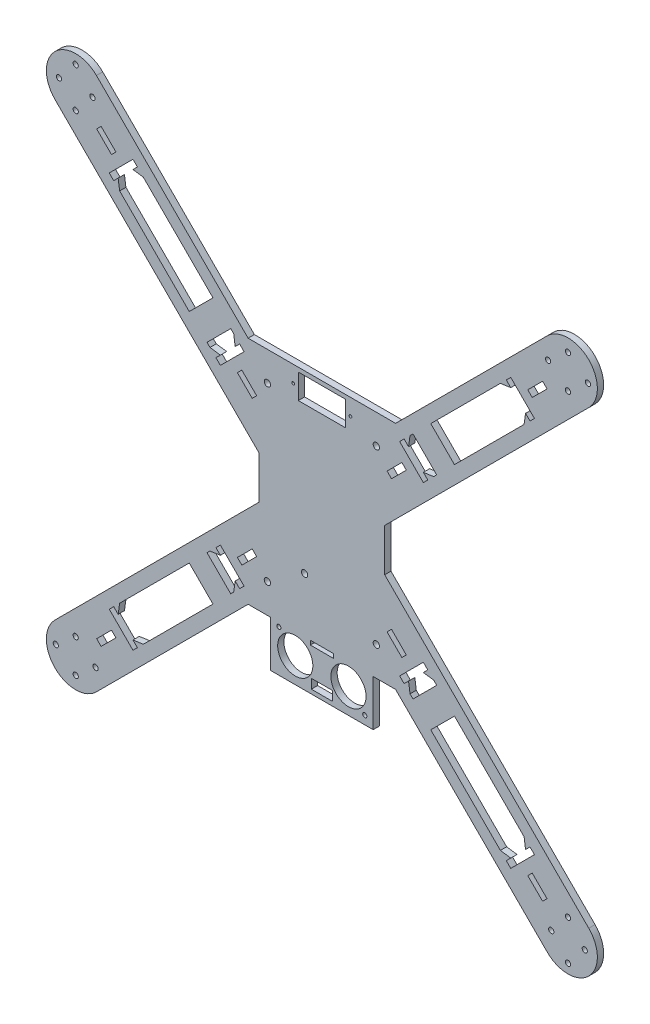
from build123d import *

# Parameters (mm, degrees)
BOSS_EXTRUDE1_DEPTH = 3
SKETCH4_R           = 1.5
SKETCH4_R_2         = 1.25
CUT_EXTRUDE1_DEPTH  = 3
SKETCH5_R           = 0.65
SKETCH5_W           = 22.5
SKETCH5_H           = 11.8
CUT_EXTRUDE2_DEPTH  = 3
SKETCH6_R           = 1.5
CUT_EXTRUDE3_DEPTH  = 3
SKETCH7_R           = 1
SKETCH7_R_2         = 8.4
SKETCH7_W           = 11
SKETCH7_H           = 2
SKETCH7_W_2         = 10
SKETCH7_H_2         = 4.5
CUT_EXTRUDE4_DEPTH  = 3
CUT_EXTRUDE5_DEPTH  = 4
BOSS_EXTRUDE2_REACH = 195.969
SKETCH9_W           = 3
SKETCH9_H           = 12
BOSS_EXTRUDE3_REACH = 195.969
SKETCH11_W          = 3
SKETCH11_H          = 12
BOSS_EXTRUDE4_REACH = 195.969
SKETCH12_W          = 3
SKETCH12_H          = 12
BOSS_EXTRUDE5_REACH = 195.969
SKETCH13_W          = 3
SKETCH13_H          = 12


with BuildPart() as part:
    # Sketch1 → Boss-Extrude1 (new body)
    with BuildSketch(Plane.XY):
        with BuildLine():
            Line((35.201010127, 55), (-35.201010127, 55))
            Line((-35.201010127, 55), (-107.600505063, 127.399494937))
            ThreePointArc((-107.600505063, 127.399494937), (-127.399494937, 127.399494937), (-127.399494937, 107.600505063))
            Line((-127.399494937, 107.600505063), (-30, 10.201010127))
            Line((-30, 10.201010127), (-30, -10.201010127))
            Line((-30, -10.201010127), (-127.399494937, -107.600505063))
            ThreePointArc((-127.399494937, -107.600505063), (-127.399494937, -127.399494937), (-107.600505063, -127.399494937))
            Line((-107.600505063, -127.399494937), (-35.201010127, -55))
            Line((-35.201010127, -55), (-24.5, -55))
            Line((-24.5, -55), (-24.5, -77))
            Line((-24.5, -77), (24.5, -77))
            Line((24.5, -77), (24.5, -55))
            Line((24.5, -55), (35.201010127, -55))
            Line((35.201010127, -55), (107.600505063, -127.399494937))
            ThreePointArc((107.600505063, -127.399494937), (127.399494937, -127.399494937), (127.399494937, -107.600505063))
            Line((127.399494937, -107.600505063), (30, -10.201010127))
            Line((30, -10.201010127), (30, 10.201010127))
            Line((30, 10.201010127), (127.399494937, 107.600505063))
            ThreePointArc((127.399494937, 107.600505063), (127.399494937, 127.399494937), (107.600505063, 127.399494937))
            Line((107.600505063, 127.399494937), (35.201010127, 55))
        make_face()
    extrude(amount=-BOSS_EXTRUDE1_DEPTH)

    # Sketch4 → Cut-Extrude1 (cut)
    with BuildSketch(Plane.XY):
        with Locations((-26, 41)):
            Circle(SKETCH4_R)
        with Locations((-26, -41)):
            Circle(SKETCH4_R)
        with Locations((26, -41)):
            Circle(SKETCH4_R)
        with Locations((26, 41)):
            Circle(SKETCH4_R)
        with Locations((-117.5, 127)):
            Circle(SKETCH4_R_2)
        with Locations((-117.5, 108)):
            Circle(SKETCH4_R_2)
        with Locations((-125.5, 117.5)):
            Circle(SKETCH4_R_2)
        with Locations((-109.5, 117.5)):
            Circle(SKETCH4_R_2)
        with Locations((117.5, 109.5)):
            Circle(SKETCH4_R_2)
        with Locations((108, 117.5)):
            Circle(SKETCH4_R_2)
        with Locations((117.5, 125.5)):
            Circle(SKETCH4_R_2)
        with Locations((127, 117.5)):
            Circle(SKETCH4_R_2)
        with Locations((109.5, -117.5)):
            Circle(SKETCH4_R_2)
        with Locations((117.5, -108)):
            Circle(SKETCH4_R_2)
        with Locations((125.5, -117.5)):
            Circle(SKETCH4_R_2)
        with Locations((117.5, -127)):
            Circle(SKETCH4_R_2)
        with Locations((-117.5, -109.5)):
            Circle(SKETCH4_R_2)
        with Locations((-108, -117.5)):
            Circle(SKETCH4_R_2)
        with Locations((-117.5, -125.5)):
            Circle(SKETCH4_R_2)
        with Locations((-127, -117.5)):
            Circle(SKETCH4_R_2)
    extrude(amount=-CUT_EXTRUDE1_DEPTH, mode=Mode.SUBTRACT)

    # Sketch5 → Cut-Extrude2 (cut)
    with BuildSketch(Plane.XY):
        with Locations((-13.65, 47.1)):
            Circle(SKETCH5_R)
        with Locations((13.65, 47.1)):
            Circle(SKETCH5_R)
        with Locations((0, 47.1)):
            Rectangle(SKETCH5_W, SKETCH5_H)
    extrude(amount=-CUT_EXTRUDE2_DEPTH, mode=Mode.SUBTRACT)

    # Sketch6 → Cut-Extrude3 (cut)
    with BuildSketch(Plane.XY):
        with Locations((-8.25, -28.8)):
            Circle(SKETCH6_R)
    extrude(amount=-CUT_EXTRUDE3_DEPTH, mode=Mode.SUBTRACT)

    # Sketch7 → Cut-Extrude4 (cut)
    with BuildSketch(Plane.XY):
        with Locations((-20.5, -57)):
            Circle(SKETCH7_R)
        with Locations((-12.7, -65)):
            Circle(SKETCH7_R_2)
        with Locations((12.7, -65)):
            Circle(SKETCH7_R_2)
        with Locations((20.5, -73)):
            Circle(SKETCH7_R)
        with Locations((0, -56)):
            Rectangle(SKETCH7_W, SKETCH7_H)
        with Locations((0, -72.75)):
            Rectangle(SKETCH7_W_2, SKETCH7_H_2)
    extrude(amount=-CUT_EXTRUDE4_DEPTH, mode=Mode.SUBTRACT)

    # Sketch8 → Cut-Extrude5 (cut, through all)
    with BuildSketch(Plane.XY):
        Polygon((101.47918472, -90.165476221), (90.165476221, -101.47918472), (88.044155877, -99.357864376), (90.165476221, -97.236544033), (85.215728753, -96.529437252), (42.0822151, -53.395923599), (41.375108319, -48.446176131), (39.253787975, -50.567496474), (37.132467632, -48.446176131), (48.446176131, -37.132467632), (50.567496474, -39.253787975), (48.446176131, -41.375108319), (53.395923599, -42.0822151), (96.529437252, -85.215728753), (97.236544033, -90.165476221), (99.357864376, -88.044155877), align=None)
        Polygon((40.314448147, -38.193127804), (38.193127804, -40.314448147), (31.122059992, -33.243380335), (33.243380335, -31.122059992), align=None)
        Polygon((50.567496474, 39.253787975), (48.446176131, 37.132467632), (37.132467632, 48.446176131), (39.253787975, 50.567496474), (41.375108319, 48.446176131), (42.0822151, 53.395923599), (85.215728753, 96.529437252), (90.165476221, 97.236544033), (88.044155877, 99.357864376), (90.165476221, 101.47918472), (101.47918472, 90.165476221), (99.357864376, 88.044155877), (97.236544033, 90.165476221), (96.529437252, 85.215728753), (53.395923599, 42.0822151), (48.446176131, 41.375108319), align=None)
        Polygon((100.418524548, -98.297204204), (98.297204204, -100.418524548), (105.368272016, -107.48959236), (107.48959236, -105.368272016), align=None)
        Polygon((-101.47918472, -90.165476221), (-99.357864376, -88.044155877), (-97.236544033, -90.165476221), (-96.529437252, -85.215728753), (-53.395923599, -42.0822151), (-48.446176131, -41.375108319), (-50.567496474, -39.253787975), (-48.446176131, -37.132467632), (-37.132467632, -48.446176131), (-39.253787975, -50.567496474), (-41.375108319, -48.446176131), (-42.0822151, -53.395923599), (-85.215728753, -96.529437252), (-90.165476221, -97.236544033), (-88.044155877, -99.357864376), (-90.165476221, -101.47918472), align=None)
        Polygon((-100.418524548, -98.297204204), (-107.48959236, -105.368272016), (-105.368272016, -107.48959236), (-98.297204204, -100.418524548), align=None)
        Polygon((-38.193127804, -40.314448147), (-40.314448147, -38.193127804), (-33.243380335, -31.122059992), (-31.122059992, -33.243380335), align=None)
        Polygon((-90.165476221, 101.47918472), (-88.044155877, 99.357864376), (-90.165476221, 97.236544033), (-85.215728753, 96.529437252), (-42.0822151, 53.395923599), (-41.375108319, 48.446176131), (-39.253787975, 50.567496474), (-37.132467632, 48.446176131), (-48.446176131, 37.132467632), (-50.567496474, 39.253787975), (-48.446176131, 41.375108319), (-53.395923599, 42.0822151), (-96.529437252, 85.215728753), (-97.236544033, 90.165476221), (-99.357864376, 88.044155877), (-101.47918472, 90.165476221), align=None)
        Polygon((-98.297204204, 100.418524548), (-105.368272016, 107.48959236), (-107.48959236, 105.368272016), (-100.418524548, 98.297204204), align=None)
        Polygon((-40.314448147, 38.193127804), (-38.193127804, 40.314448147), (-31.122059992, 33.243380335), (-33.243380335, 31.122059992), align=None)
        Polygon((100.418524548, 98.297204204), (107.48959236, 105.368272016), (105.368272016, 107.48959236), (98.297204204, 100.418524548), align=None)
        Polygon((38.193127804, 40.314448147), (40.314448147, 38.193127804), (33.243380335, 31.122059992), (31.122059992, 33.243380335), align=None)
    extrude(amount=-CUT_EXTRUDE5_DEPTH, mode=Mode.SUBTRACT)

    # Sketch9 → Boss-Extrude2 (add, up to next)
    with BuildSketch(Plane(origin=(-5.656854249, 5.656854249, 0), x_dir=(0, 0, -1), z_dir=(0.707106781, -0.707106781, 0)), mode=Mode.PRIVATE) as boss_extrude2_sk1:
        with Locations((1.5, 75.513239329)):
            Rectangle(SKETCH9_W, SKETCH9_H)
    boss_extrude2_tool1 = extrude(boss_extrude2_sk1.sketch, amount=BOSS_EXTRUDE2_REACH, mode=Mode.PRIVATE) - part.part
    add(boss_extrude2_tool1.solids().sort_by_distance((47.739069, 59.052778, -1.5))[0])

    # Sketch11 → Boss-Extrude3 (add, up to next)
    with BuildSketch(Plane(origin=(5.656854249, 5.656854249, 0), x_dir=(0, 0, 1), z_dir=(-0.707106781, -0.707106781, 0)), mode=Mode.PRIVATE) as boss_extrude3_sk1:
        with Locations((-1.5, -75.513239329)):
            Rectangle(SKETCH11_W, SKETCH11_H)
    boss_extrude3_tool1 = extrude(boss_extrude3_sk1.sketch, amount=BOSS_EXTRUDE3_REACH, mode=Mode.PRIVATE) - part.part
    add(boss_extrude3_tool1.solids().sort_by_distance((59.052778, -47.739069, -1.5))[0])

    # Sketch12 → Boss-Extrude4 (add, up to next)
    with BuildSketch(Plane(origin=(5.656854249, -5.656854249, 0), x_dir=(0, 0, 1), z_dir=(-0.707106781, 0.707106781, 0)), mode=Mode.PRIVATE) as boss_extrude4_sk1:
        with Locations((-1.5, -75.513239329)):
            Rectangle(SKETCH12_W, SKETCH12_H)
    boss_extrude4_tool1 = extrude(boss_extrude4_sk1.sketch, amount=BOSS_EXTRUDE4_REACH, mode=Mode.PRIVATE) - part.part
    add(boss_extrude4_tool1.solids().sort_by_distance((-47.739069, -59.052778, -1.5))[0])

    # Sketch13 → Boss-Extrude5 (add, up to next)
    with BuildSketch(Plane(origin=(5.656854249, 5.656854249, 0), x_dir=(0, 0, 1), z_dir=(-0.707106781, -0.707106781, 0)), mode=Mode.PRIVATE) as boss_extrude5_sk1:
        with Locations((-1.5, 75.513239329)):
            Rectangle(SKETCH13_W, SKETCH13_H)
    boss_extrude5_tool1 = extrude(boss_extrude5_sk1.sketch, amount=BOSS_EXTRUDE5_REACH, mode=Mode.PRIVATE) - part.part
    add(boss_extrude5_tool1.solids().sort_by_distance((-47.739069, 59.052778, -1.5))[0])


solid = part.part
